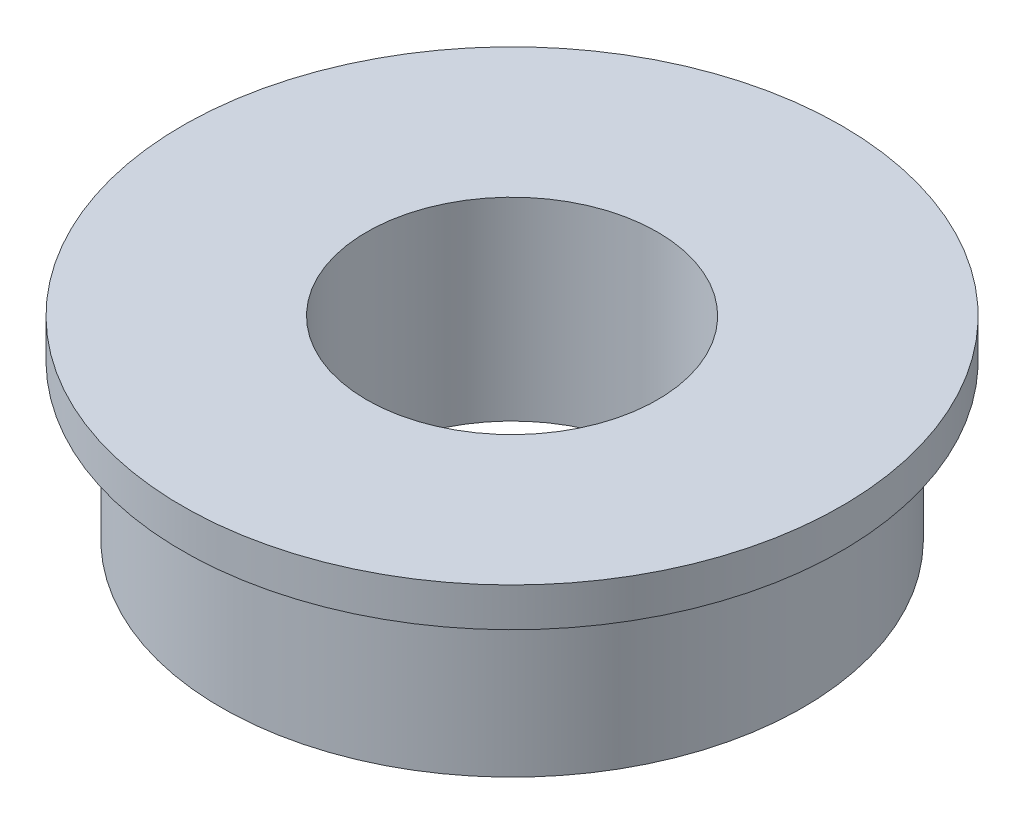
from build123d import *


with BuildPart() as part:
    # Esquisse1 → Révolution1 (revolve)
    with BuildSketch(Plane.XY):
        Polygon((3, 4), (6.8, 4), (6.8, 3.2), (6, 3.2), (6, 0), (3, 0), align=None)
    revolve(axis=Axis((0, 0, 0), (0, 1, 0)))


solid = part.part
